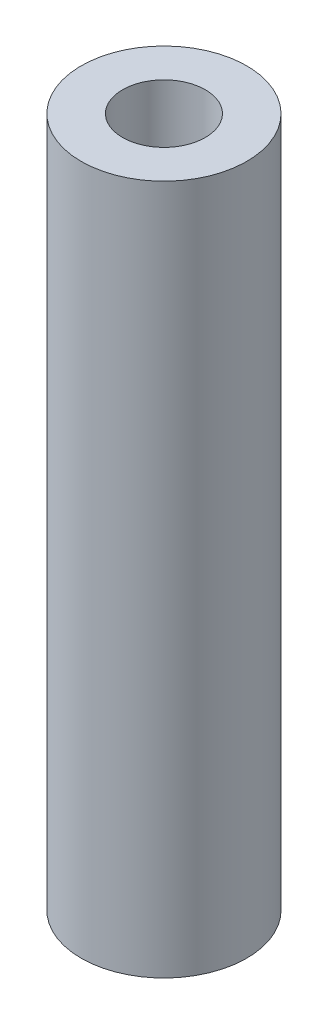
from build123d import *

# Parameters (mm, degrees)
SKETCH1_R           = 3
SKETCH1_R_2         = 1.5
BOSS_EXTRUDE1_DEPTH = 25


with BuildPart() as part:
    # Sketch1 → Boss-Extrude1 (new body)
    with BuildSketch(Plane(origin=(0, 0, 0), x_dir=(1, 0, 0), z_dir=(0, 1, 0))):
        Circle(SKETCH1_R)
        Circle(SKETCH1_R_2, mode=Mode.SUBTRACT)
    extrude(amount=BOSS_EXTRUDE1_DEPTH)


solid = part.part
